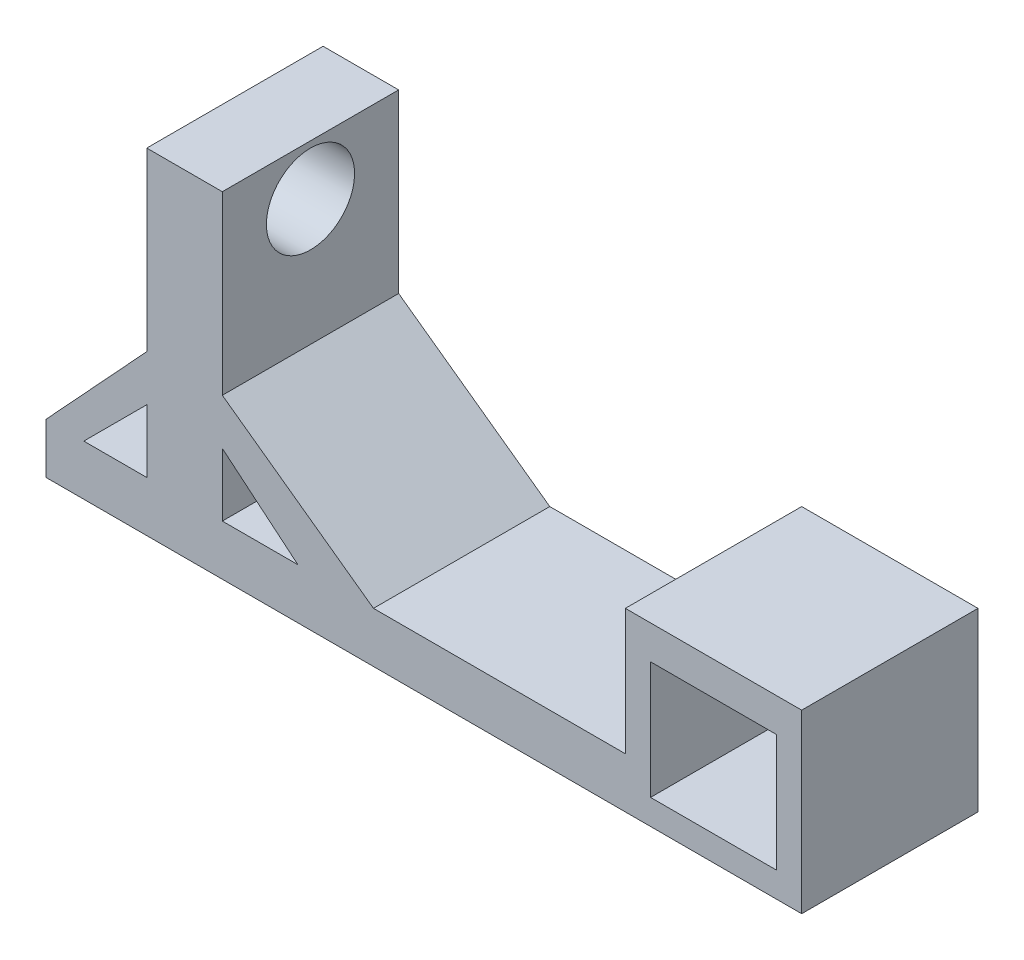
from build123d import *

# Parameters (mm, degrees)
EXTRUDE_1_DEPTH     = 70
SKETCH_2_W          = 50
SKETCH_2_H          = 46.62381926
CUT_EXTRUDE_1_DEPTH = 70
CUT_EXTRUDE_2_REACH = 72
SKETCH_3_R          = 17.5
CUT_EXTRUDE_3_DEPTH = 70


with BuildPart() as part:
    # 草图1 → 凸台-拉伸1 (new body)
    with BuildSketch(Plane.XY):
        Polygon((-65.25, 63.25), (-65.25, -6.75), (-105.25, -50), (-105.25, -70), (194.75, -70), (194.75, 0), (124.75, 0), (124.75, -50), (24.75, -50), (-35.25, -6.75), (-35.25, 63.25), align=None)
    extrude(amount=EXTRUDE_1_DEPTH)

    # 草图2 → 切除-拉伸1 (cut)
    with BuildSketch(Plane.XY.offset(70)):
        with Locations((159.75, -36.68809037)):
            Rectangle(SKETCH_2_W, SKETCH_2_H)
    extrude(amount=-CUT_EXTRUDE_1_DEPTH, mode=Mode.SUBTRACT)

    # 草图3 → 切除-拉伸2 (cut, up to next)
    with BuildSketch(Plane(origin=(-35.25, 0, 0), x_dir=(0, 0, -1), z_dir=(1, 0, 0)), mode=Mode.PRIVATE) as cut_extrude_2_sk1:
        with Locations((-35, 43.25)):
            Circle(SKETCH_3_R)
    cut_extrude_2_tool1 = extrude(cut_extrude_2_sk1.sketch, amount=-CUT_EXTRUDE_2_REACH, mode=Mode.PRIVATE) & part.part
    add(cut_extrude_2_tool1.solids().sort_by_distance((-35.25, 43.25, 35))[0], mode=Mode.SUBTRACT)

    # 草图4 → 切除-拉伸3 (cut)
    with BuildSketch(Plane.XY.offset(70)):
        Polygon((-65.25, -25), (-90.25, -50), (-65.25, -50), align=None)
        Polygon((-35.25, -25), (-35.25, -50), (-5.25, -50), align=None)
    extrude(amount=-CUT_EXTRUDE_3_DEPTH, mode=Mode.SUBTRACT)


solid = part.part
